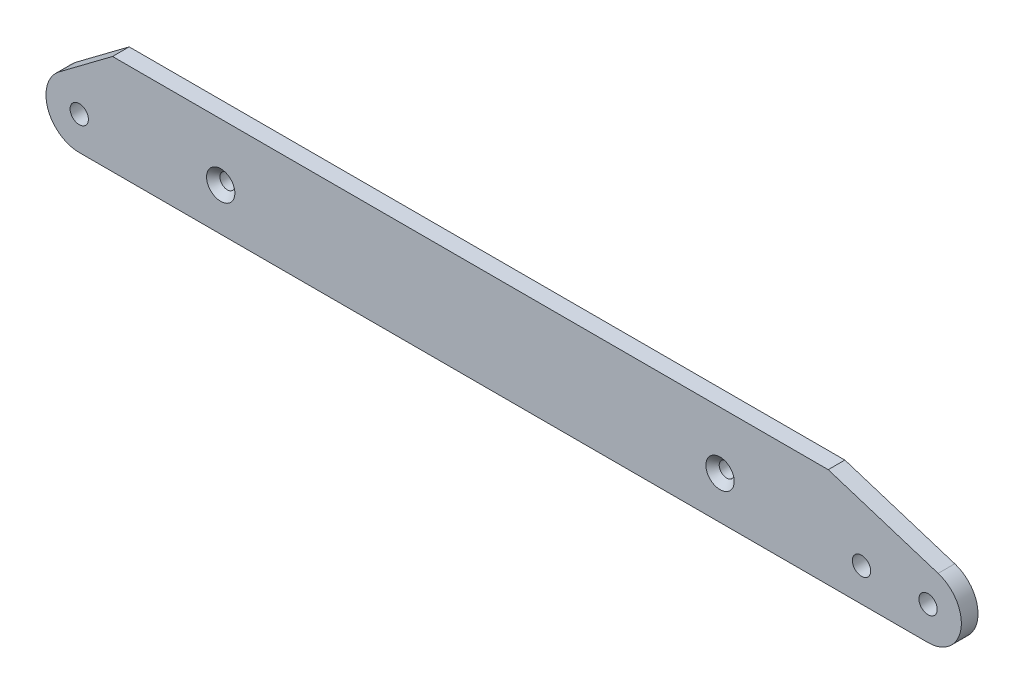
from build123d import *

# Parameters (mm, degrees)
SKETCH1_R           = 2.25
SKETCH1_R_2         = 2.75
BOSS_EXTRUDE1_DEPTH = 2.5
CHAMFER1_SIZE       = 2


with BuildPart() as part:
    # Sketch1 → Boss-Extrude1 (new body, symmetric)
    with BuildSketch(Plane.XY):
        with BuildLine():
            Line((-117.5, -12.8), (137.5, -12.8))
            ThreePointArc((137.5, -12.8), (147.382444583, -4.328819498), (140.521694793, 6.732542189))
            Line((140.521694793, 6.732542189), (107.5, 17.2))
            Line((107.5, 17.2), (-107.5, 17.2))
            Line((-107.5, 17.2), (-123.5, 5.2))
            ThreePointArc((-123.5, 5.2), (-126.986832981, -5.96227766), (-117.5, -12.8))
        make_face()
        with Locations((75, 0)):
            Circle(SKETCH1_R, mode=Mode.SUBTRACT)
        with Locations((-75, 0)):
            Circle(SKETCH1_R, mode=Mode.SUBTRACT)
        with Locations((-117.5, -2.8)):
            Circle(SKETCH1_R_2, mode=Mode.SUBTRACT)
        with Locations((117.5, -2.8)):
            Circle(SKETCH1_R_2, mode=Mode.SUBTRACT)
        with Locations((137.5, -2.8)):
            Circle(SKETCH1_R_2, mode=Mode.SUBTRACT)
    extrude(amount=BOSS_EXTRUDE1_DEPTH, both=True)

    # Chamfer1
    chamfer1_edges = [part.edges().sort_by_distance(p)[0] for p in [
        (-77.25, 0, 2.5),
        (72.75, 0, 2.5),
    ]]
    chamfer(chamfer1_edges, length=CHAMFER1_SIZE)


solid = part.part
